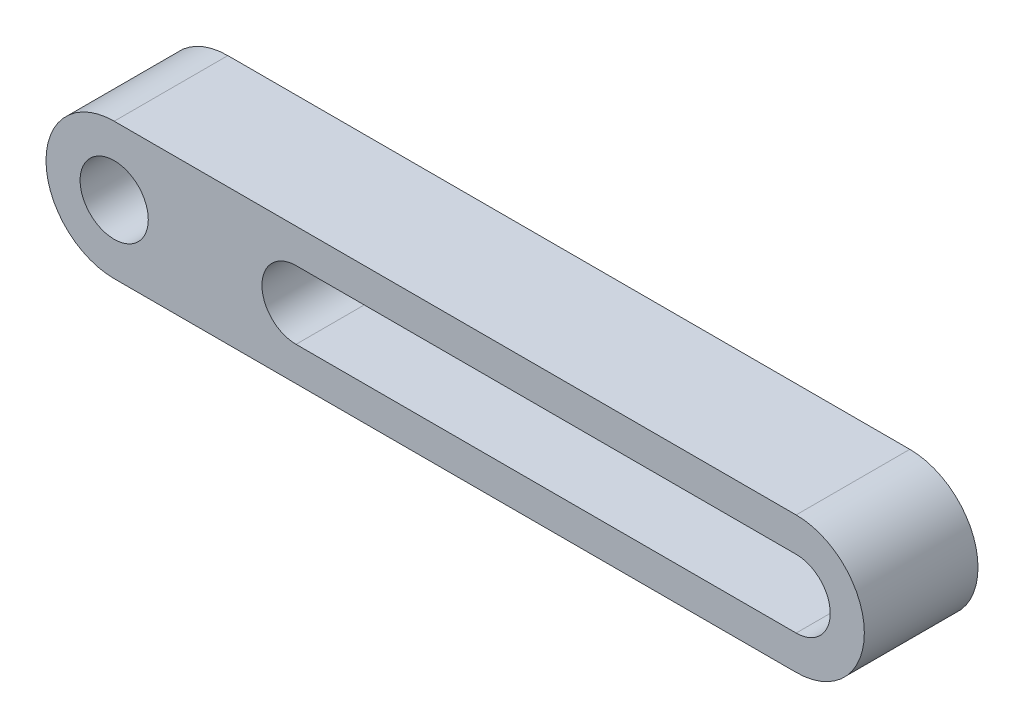
from build123d import *

# Parameters (mm, degrees)
SKETCH1_R           = 1.5
BOSS_EXTRUDE1_DEPTH = 5


with BuildPart() as part:
    # Sketch1 → Boss-Extrude1 (new body)
    with BuildSketch(Plane.XY):
        with BuildLine():
            Line((0, 3), (30, 3))
            ThreePointArc((30, 3), (33, 0), (30, -3))
            Line((30, -3), (0, -3))
            ThreePointArc((0, -3), (-3, 0), (0, 3))
        make_face()
        Circle(SKETCH1_R, mode=Mode.SUBTRACT)
        with BuildLine():
            Line((30, -1.5), (8, -1.5))
            ThreePointArc((8, -1.5), (6.5, 0), (8, 1.5))
            Line((8, 1.5), (30, 1.5))
            ThreePointArc((30, 1.5), (31.5, 0), (30, -1.5))
        make_face(mode=Mode.SUBTRACT)
    extrude(amount=BOSS_EXTRUDE1_DEPTH)


solid = part.part
